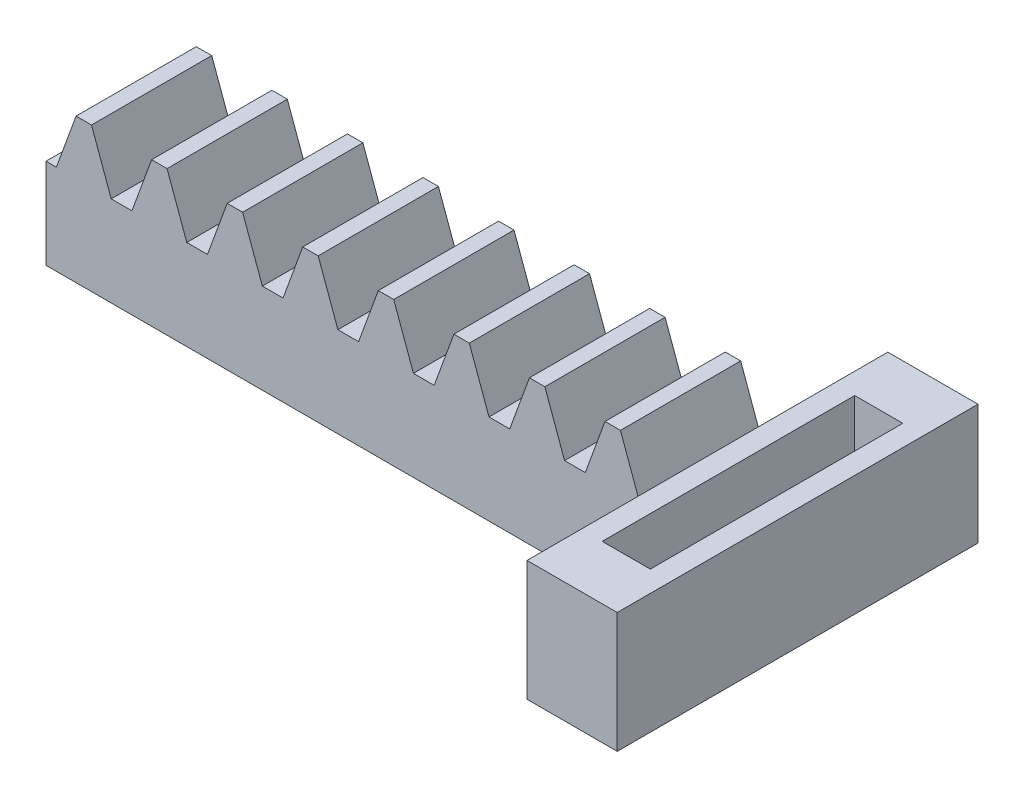
from build123d import *

# Parameters (mm, degrees)
BOSS_EXTRUDE1_DEPTH = 10
SKETCH2_W           = 30
SKETCH2_H           = 10
BOSS_EXTRUDE2_DEPTH = 7.5
CUT_EXTRUDE1_REACH  = 12
SKETCH3_W           = 4
SKETCH3_H           = 21


with BuildPart() as part:
    # Sketch1 → Boss-Extrude1 (new body)
    with BuildSketch(Plane(origin=(0, 0, -10.04783639), x_dir=(-1, 0, 0), z_dir=(0, 0, -1))):
        Polygon((24.605530087, 10.619804964), (22.967664033, 6.119804964), (22.371275694, 6.119804964), (22.371275694, -1.380195036), (72.371275694, -1.380195036), (72.371275694, 6.119804964), (71.509404954, 6.119804964), (69.8715389, 10.619804964), (68.587827187, 10.619804964), (66.949961133, 6.119804964), (65.226219654, 6.119804964), (63.5883536, 10.619804964), (62.304641887, 10.619804964), (60.666775833, 6.119804964), (58.943034354, 6.119804964), (57.3051683, 10.619804964), (56.021456587, 10.619804964), (54.383590533, 6.119804964), (52.659849054, 6.119804964), (51.021983, 10.619804964), (49.738271287, 10.619804964), (48.100405233, 6.119804964), (46.376663754, 6.119804964), (44.7387977, 10.619804964), (43.455085987, 10.619804964), (41.817219933, 6.119804964), (40.093478454, 6.119804964), (38.4556124, 10.619804964), (37.171900687, 10.619804964), (35.534034633, 6.119804964), (33.810293154, 6.119804964), (32.1724271, 10.619804964), (30.888715387, 10.619804964), (29.250849333, 6.119804964), (27.527107854, 6.119804964), (25.8892418, 10.619804964), align=None)
    extrude(amount=-BOSS_EXTRUDE1_DEPTH)

    # Sketch2 → Boss-Extrude2 (add)
    with BuildSketch(Plane(origin=(-22.371275694, 0, 0), x_dir=(0, 0, -1), z_dir=(1, 0, 0))):
        with Locations((5.04783639, 2.369804964)):
            Rectangle(SKETCH2_W, SKETCH2_H)
    extrude(amount=BOSS_EXTRUDE2_DEPTH)

    # Sketch3 → Cut-Extrude1 (cut, up to next)
    with BuildSketch(Plane(origin=(0, 7.369804964, 0), x_dir=(-1, 0, 0), z_dir=(0, 1, 0)), mode=Mode.PRIVATE) as cut_extrude1_sk1:
        with Locations((18.621275694, -5.04783639)):
            Rectangle(SKETCH3_W, SKETCH3_H)
    cut_extrude1_tool1 = extrude(cut_extrude1_sk1.sketch, amount=-CUT_EXTRUDE1_REACH, mode=Mode.PRIVATE) & part.part
    add(cut_extrude1_tool1.solids().sort_by_distance((-18.621276, 7.369805, -5.047836))[0], mode=Mode.SUBTRACT)


solid = part.part
